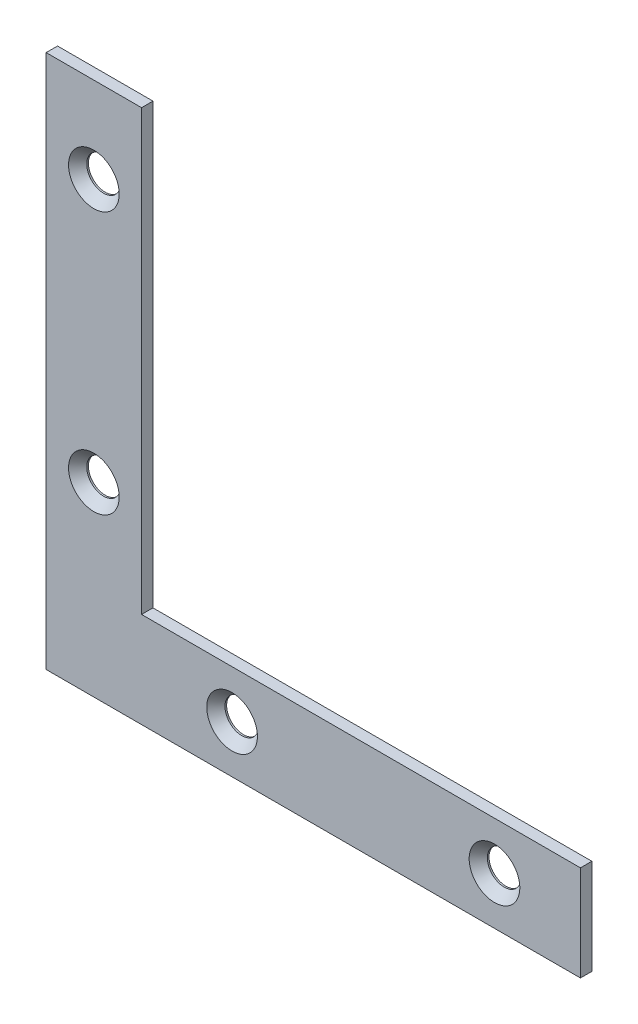
from build123d import *

# Parameters (mm, degrees)
BOSS_EXTRUDE1_DEPTH      = 0.94869
BOSS_EXTRUDE1_DEPTH_BACK = 0.94869
SKETCH4_R                = 2.8067
CUT_EXTRUDE1_DEPTH       = 1.94869
CUT_EXTRUDE1_DEPTH_BACK  = 1.94869
SKETCH5_R                = 4.2164
CUT_EXTRUDE2_DEPTH       = 2.89738
CUT_EXTRUDE2_TAPER       = 41


with BuildPart() as part:
    # Sketch3 → Boss-Extrude1 (new body, two sides)
    with BuildSketch(Plane.XY) as boss_extrude1_sk:
        Polygon((-44.45, 44.45), (-28.575, 44.45), (-28.575, -28.575), (44.45, -28.575), (44.45, -44.45), (-44.45, -44.45), align=None)
    extrude(amount=BOSS_EXTRUDE1_DEPTH)
    extrude(boss_extrude1_sk.sketch, amount=-BOSS_EXTRUDE1_DEPTH_BACK)

    # Sketch4 → Cut-Extrude1 (cut, two sides)
    with BuildSketch(Plane.XY) as cut_extrude1_sk:
        with Locations((-36.5125, 30.1498)):
            Circle(SKETCH4_R)
        with Locations((-36.5125, -13.5128)):
            Circle(SKETCH4_R)
        with Locations((-13.5128, -36.5125)):
            Circle(SKETCH4_R)
        with Locations((30.1498, -36.5125)):
            Circle(SKETCH4_R)
    extrude(amount=CUT_EXTRUDE1_DEPTH, mode=Mode.SUBTRACT)
    extrude(cut_extrude1_sk.sketch, amount=-CUT_EXTRUDE1_DEPTH_BACK, mode=Mode.SUBTRACT)

    # Sketch5 → Cut-Extrude2 (cut, through all)
    with BuildSketch(Plane.XY.offset(0.94869)):
        with Locations((-36.5125, 30.1498)):
            Circle(SKETCH5_R)
        with Locations((-36.5125, -13.5128)):
            Circle(SKETCH5_R)
        with Locations((-13.5128, -36.5125)):
            Circle(SKETCH5_R)
        with Locations((30.1498, -36.5125)):
            Circle(SKETCH5_R)
    extrude(amount=-CUT_EXTRUDE2_DEPTH, taper=CUT_EXTRUDE2_TAPER, mode=Mode.SUBTRACT)


solid = part.part
